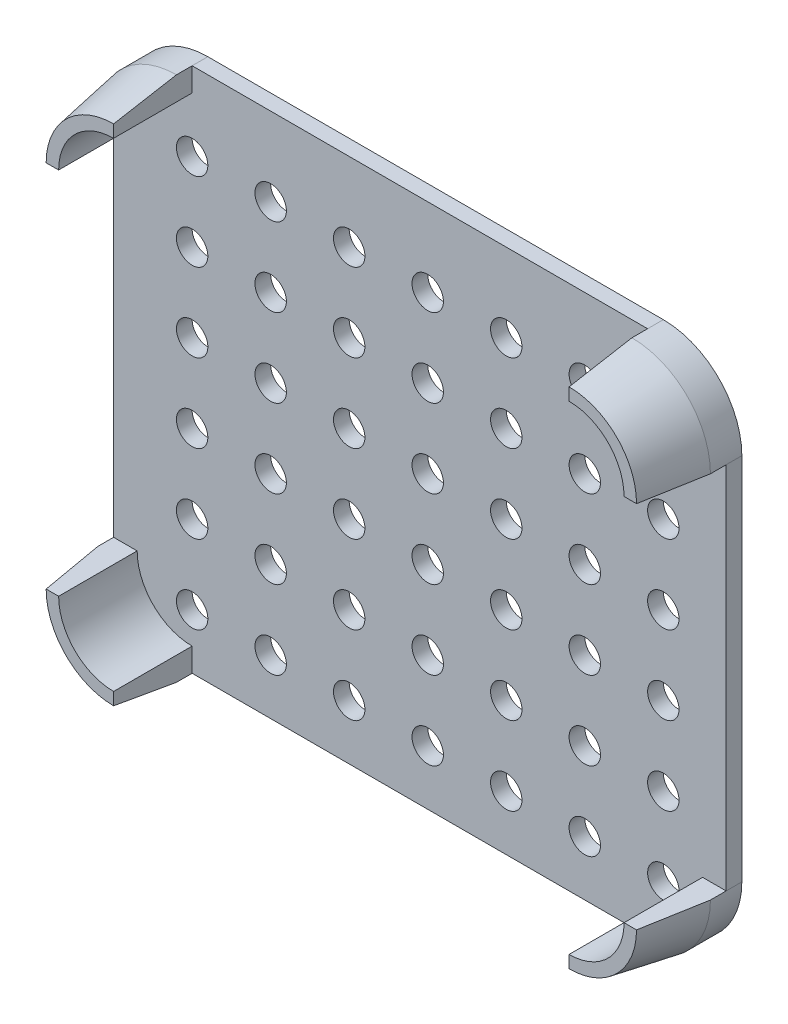
from build123d import *

# Parameters (mm, degrees)
ESQUISSE1_R             = 2
BOSS_EXTRU_1_DEPTH      = 2
BOSS_EXTRU_2_DEPTH      = 10
CHANFREIN1_SIZE         = 8
CHANFREIN1_SIZE2        = 1.410615846
CHANFREIN1_PART_2_SIZE  = 8
CHANFREIN1_PART_2_SIZE2 = 1.410615846
CHANFREIN1_PART_3_SIZE  = 8
CHANFREIN1_PART_3_SIZE2 = 1.410615846
CHANFREIN1_PART_4_SIZE  = 8
CHANFREIN1_PART_4_SIZE2 = 1.410615846


with BuildPart() as part:
    # Esquisse1 → Boss.-Extru.1 (new body)
    with BuildSketch(Plane.XY):
        with BuildLine():
            Line((10, 0), (68, 0))
            ThreePointArc((68, 0), (75.071067812, 2.928932188), (78, 10))
            Line((78, 10), (78, 57))
            ThreePointArc((78, 57), (75.071067812, 64.071067812), (68, 67))
            Line((68, 67), (10, 67))
            ThreePointArc((10, 67), (2.928932188, 64.071067812), (0, 57))
            Line((0, 57), (0, 10))
            ThreePointArc((0, 10), (2.928932188, 2.928932188), (10, 0))
        make_face()
        with Locations((10, 57)):
            Circle(ESQUISSE1_R, mode=Mode.SUBTRACT)
        with Locations((20, 57)):
            Circle(ESQUISSE1_R, mode=Mode.SUBTRACT)
        with Locations((30, 57)):
            Circle(ESQUISSE1_R, mode=Mode.SUBTRACT)
        with Locations((40, 57)):
            Circle(ESQUISSE1_R, mode=Mode.SUBTRACT)
        with Locations((50, 57)):
            Circle(ESQUISSE1_R, mode=Mode.SUBTRACT)
        with Locations((60, 57)):
            Circle(ESQUISSE1_R, mode=Mode.SUBTRACT)
        with Locations((70, 57)):
            Circle(ESQUISSE1_R, mode=Mode.SUBTRACT)
        with Locations((20, 47)):
            Circle(ESQUISSE1_R, mode=Mode.SUBTRACT)
        with Locations((30, 47)):
            Circle(ESQUISSE1_R, mode=Mode.SUBTRACT)
        with Locations((40, 47)):
            Circle(ESQUISSE1_R, mode=Mode.SUBTRACT)
        with Locations((50, 47)):
            Circle(ESQUISSE1_R, mode=Mode.SUBTRACT)
        with Locations((60, 47)):
            Circle(ESQUISSE1_R, mode=Mode.SUBTRACT)
        with Locations((70, 47)):
            Circle(ESQUISSE1_R, mode=Mode.SUBTRACT)
        with Locations((20, 37)):
            Circle(ESQUISSE1_R, mode=Mode.SUBTRACT)
        with Locations((30, 37)):
            Circle(ESQUISSE1_R, mode=Mode.SUBTRACT)
        with Locations((40, 37)):
            Circle(ESQUISSE1_R, mode=Mode.SUBTRACT)
        with Locations((50, 37)):
            Circle(ESQUISSE1_R, mode=Mode.SUBTRACT)
        with Locations((60, 37)):
            Circle(ESQUISSE1_R, mode=Mode.SUBTRACT)
        with Locations((70, 37)):
            Circle(ESQUISSE1_R, mode=Mode.SUBTRACT)
        with Locations((20, 27)):
            Circle(ESQUISSE1_R, mode=Mode.SUBTRACT)
        with Locations((30, 27)):
            Circle(ESQUISSE1_R, mode=Mode.SUBTRACT)
        with Locations((40, 27)):
            Circle(ESQUISSE1_R, mode=Mode.SUBTRACT)
        with Locations((50, 27)):
            Circle(ESQUISSE1_R, mode=Mode.SUBTRACT)
        with Locations((60, 27)):
            Circle(ESQUISSE1_R, mode=Mode.SUBTRACT)
        with Locations((70, 27)):
            Circle(ESQUISSE1_R, mode=Mode.SUBTRACT)
        with Locations((20, 17)):
            Circle(ESQUISSE1_R, mode=Mode.SUBTRACT)
        with Locations((30, 17)):
            Circle(ESQUISSE1_R, mode=Mode.SUBTRACT)
        with Locations((40, 17)):
            Circle(ESQUISSE1_R, mode=Mode.SUBTRACT)
        with Locations((50, 17)):
            Circle(ESQUISSE1_R, mode=Mode.SUBTRACT)
        with Locations((60, 17)):
            Circle(ESQUISSE1_R, mode=Mode.SUBTRACT)
        with Locations((70, 17)):
            Circle(ESQUISSE1_R, mode=Mode.SUBTRACT)
        with Locations((20, 7)):
            Circle(ESQUISSE1_R, mode=Mode.SUBTRACT)
        with Locations((30, 7)):
            Circle(ESQUISSE1_R, mode=Mode.SUBTRACT)
        with Locations((40, 7)):
            Circle(ESQUISSE1_R, mode=Mode.SUBTRACT)
        with Locations((50, 7)):
            Circle(ESQUISSE1_R, mode=Mode.SUBTRACT)
        with Locations((60, 7)):
            Circle(ESQUISSE1_R, mode=Mode.SUBTRACT)
        with Locations((70, 7)):
            Circle(ESQUISSE1_R, mode=Mode.SUBTRACT)
        with Locations((10, 47)):
            Circle(ESQUISSE1_R, mode=Mode.SUBTRACT)
        with Locations((10, 37)):
            Circle(ESQUISSE1_R, mode=Mode.SUBTRACT)
        with Locations((10, 27)):
            Circle(ESQUISSE1_R, mode=Mode.SUBTRACT)
        with Locations((10, 17)):
            Circle(ESQUISSE1_R, mode=Mode.SUBTRACT)
        with Locations((10, 7)):
            Circle(ESQUISSE1_R, mode=Mode.SUBTRACT)
    extrude(amount=BOSS_EXTRU_1_DEPTH)

    # Esquisse2 → Boss.-Extru.2 (add)
    with BuildSketch(Plane.XY.offset(2)):
        with BuildLine():
            Line((10, 67), (10, 64))
            ThreePointArc((10, 64), (5.050252532, 61.949747468), (3, 57))
            Line((3, 57), (0, 57))
            ThreePointArc((0, 57), (2.928932188, 64.071067812), (10, 67))
        make_face()
        with BuildLine():
            Line((0, 10), (3, 10))
            ThreePointArc((3, 10), (5.050252532, 5.050252532), (10, 3))
            Line((10, 3), (10, 0))
            ThreePointArc((10, 0), (2.928932188, 2.928932188), (0, 10))
        make_face()
        with BuildLine():
            Line((75, 10), (78, 10))
            ThreePointArc((78, 10), (75.071067812, 2.928932188), (68, 0))
            Line((68, 0), (68, 3))
            ThreePointArc((68, 3), (72.949747468, 5.050252532), (75, 10))
        make_face()
        with BuildLine():
            Line((78, 57), (75, 57))
            ThreePointArc((75, 57), (72.949747468, 61.949747468), (68, 64))
            Line((68, 64), (68, 67))
            ThreePointArc((68, 67), (75.071067812, 64.071067812), (78, 57))
        make_face()
    extrude(amount=BOSS_EXTRU_2_DEPTH)

    # Chanfrein1
    chanfrein1_edges = [part.edges().sort_by_distance(p)[0] for p in [
        (2.928932188, 64.071067812, 12),
    ]]
    chanfrein1_side = [part.faces().sort_by_distance(p)[0] for p in [
        (2.928932188, 64.071067812, 6),
    ]]
    chamfer(chanfrein1_edges, length=CHANFREIN1_SIZE, length2=CHANFREIN1_SIZE2, reference=chanfrein1_side[0])

    # Chanfrein1 part 2
    chanfrein1_part_2_edges = [part.edges().sort_by_distance(p)[0] for p in [
        (2.928932188, 2.928932188, 12),
    ]]
    chanfrein1_part_2_side = [part.faces().sort_by_distance(p)[0] for p in [
        (2.928932188, 2.928932188, 6),
    ]]
    chamfer(chanfrein1_part_2_edges, length=CHANFREIN1_PART_2_SIZE, length2=CHANFREIN1_PART_2_SIZE2, reference=chanfrein1_part_2_side[0])

    # Chanfrein1 part 3
    chanfrein1_part_3_edges = [part.edges().sort_by_distance(p)[0] for p in [
        (75.071067812, 64.071067812, 12),
    ]]
    chanfrein1_part_3_side = [part.faces().sort_by_distance(p)[0] for p in [
        (75.071067812, 64.071067812, 6),
    ]]
    chamfer(chanfrein1_part_3_edges, length=CHANFREIN1_PART_3_SIZE, length2=CHANFREIN1_PART_3_SIZE2, reference=chanfrein1_part_3_side[0])

    # Chanfrein1 part 4
    chanfrein1_part_4_edges = [part.edges().sort_by_distance(p)[0] for p in [
        (75.071067812, 2.928932188, 12),
    ]]
    chanfrein1_part_4_side = [part.faces().sort_by_distance(p)[0] for p in [
        (75.071067812, 2.928932188, 6),
    ]]
    chamfer(chanfrein1_part_4_edges, length=CHANFREIN1_PART_4_SIZE, length2=CHANFREIN1_PART_4_SIZE2, reference=chanfrein1_part_4_side[0])


solid = part.part
